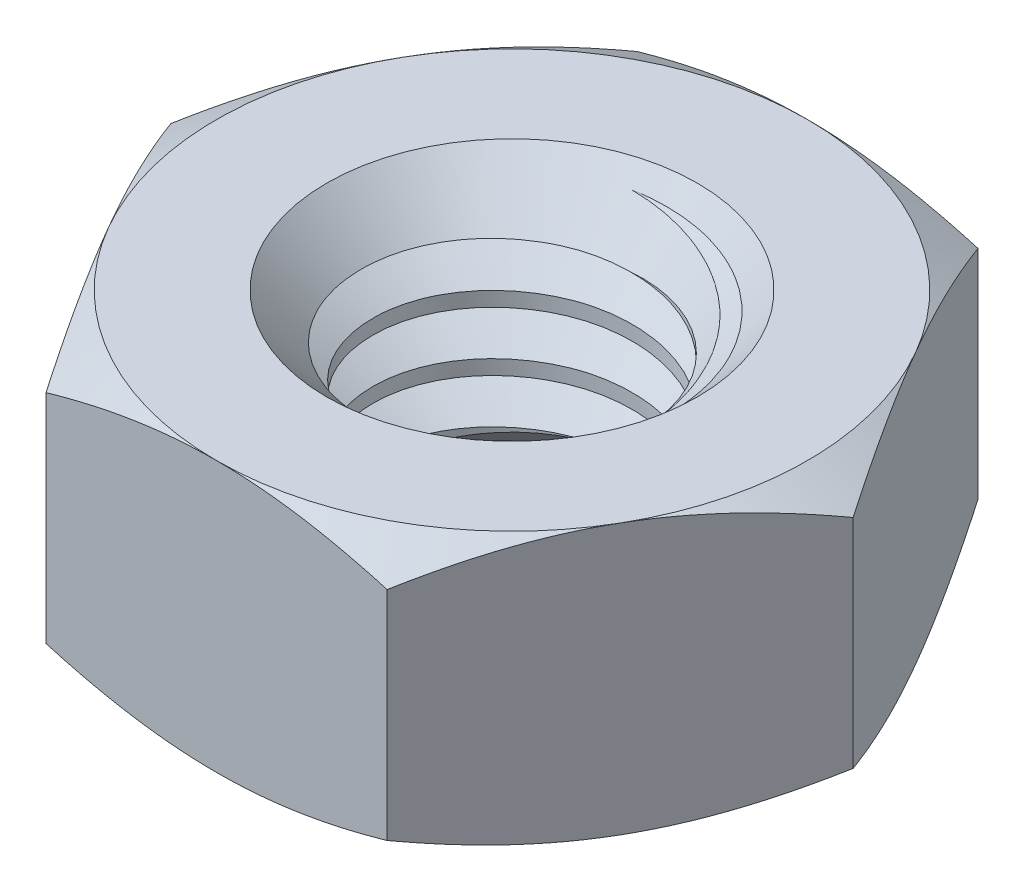
from build123d import *

# Parameters (mm, degrees)
Y_KSEKLIK_EKSTR_ZYON1_DEPTH = 3.2
IZIM2_OUTSIDE_W             = 23.4
IZIM2_OUTSIDE_H             = 22.318
IZIM2_OUTSIDE_R             = 3.5
KES_EKSTR_ZYON1_DEPTH       = 3.2
KES_EKSTR_ZYON1_DRAFT       = -60
IZIM3_OUTSIDE_W             = 23.4
IZIM3_OUTSIDE_H             = 22.318
IZIM3_OUTSIDE_R             = 3.5
KES_EKSTR_ZYON2_DEPTH       = 3.2
KES_EKSTR_ZYON2_DRAFT       = -60
IZIM5_R                     = 1.545
KES_EKSTR_ZYON3_DEPTH       = 3.2
PAH1_SIZE                   = 0.65
KES_S_P_R1_PITCH            = 0.7
KES_S_P_R1_HEIGHT           = 4
KES_S_P_R1_RADIUS           = 1.545
BODY_MOVE_COPY1_ANGLE       = 90


with BuildPart() as part:
    # Çizim1 → Yükseklik-Ekstrüzyon1 (new body)
    with BuildSketch(Plane.XY):
        Polygon((4.041451884, 0), (2.020725942, 3.5), (-2.020725942, 3.5), (-4.041451884, 0), (-2.020725942, -3.5), (2.020725942, -3.5), align=None)
    extrude(amount=Y_KSEKLIK_EKSTR_ZYON1_DEPTH)


with BuildPart() as kes_ekstr_zyon1_tool:
    # Çizim2 outside → Kes-Ekstrüzyon1 (with draft: the straight prism first)
    with BuildSketch(Plane.XY.offset(3.2)):
        Rectangle(IZIM2_OUTSIDE_W, IZIM2_OUTSIDE_H)
        Circle(IZIM2_OUTSIDE_R, mode=Mode.SUBTRACT)
    extrude(amount=-KES_EKSTR_ZYON1_DEPTH)
    # Kes-Ekstrüzyon1: the draft: its side faces are tilted about the plane it starts from
    kes_ekstr_zyon1_sides = [kes_ekstr_zyon1_tool.faces().sort_by_distance(p)[0] for p in [
        (0, -11.159, 1.6),
        (11.7, 0, 1.6),
        (0, 11.159, 1.6),
        (-11.7, 0, 1.6),
        (-3.5, 0, 1.6),
    ]]
    draft(kes_ekstr_zyon1_sides, Plane.XY.offset(3.2), KES_EKSTR_ZYON1_DRAFT)


with BuildPart() as part_1:
    add(part.part)

    # Kes-Ekstrüzyon1: cut by kes_ekstr_zyon1_tool
    add(kes_ekstr_zyon1_tool.part, mode=Mode.SUBTRACT)


with BuildPart() as kes_ekstr_zyon2_tool:
    # Çizim3 outside → Kes-Ekstrüzyon2 (with draft: the straight prism first)
    with BuildSketch(Plane(origin=(0, 0, 0), x_dir=(-1, 0, 0), z_dir=(0, 0, -1))):
        Rectangle(IZIM3_OUTSIDE_W, IZIM3_OUTSIDE_H)
        Circle(IZIM3_OUTSIDE_R, mode=Mode.SUBTRACT)
    extrude(amount=-KES_EKSTR_ZYON2_DEPTH)
    # Kes-Ekstrüzyon2: the draft: its side faces are tilted about the plane it starts from
    kes_ekstr_zyon2_sides = [kes_ekstr_zyon2_tool.faces().sort_by_distance(p)[0] for p in [
        (0, -11.159, 1.6),
        (-11.7, 0, 1.6),
        (0, 11.159, 1.6),
        (11.7, 0, 1.6),
        (3.5, 0, 1.6),
    ]]
    draft(kes_ekstr_zyon2_sides, Plane(origin=(0, 0, 0), x_dir=(-1, 0, 0), z_dir=(0, 0, -1)), KES_EKSTR_ZYON2_DRAFT)


with BuildPart() as part_2:
    add(part_1.part)

    # Kes-Ekstrüzyon2: cut by kes_ekstr_zyon2_tool
    add(kes_ekstr_zyon2_tool.part, mode=Mode.SUBTRACT)

    # Çizim5 → Kes-Ekstrüzyon3 (cut)
    with BuildSketch(Plane(origin=(0, 0, 0), x_dir=(-1, 0, 0), z_dir=(0, 0, -1))):
        Circle(IZIM5_R)
    extrude(amount=-KES_EKSTR_ZYON3_DEPTH, mode=Mode.SUBTRACT)

    # Pah1
    pah1_edges = [part_2.edges().sort_by_distance(p)[0] for p in [
        (1.545, 0, 3.2),
        (1.545, 0, 0),
    ]]
    chamfer(pah1_edges, length=PAH1_SIZE)

    # Kes-Süpür1: sweep along a helix
    with BuildLine() as kes_s_p_r1_path:
        Helix(KES_S_P_R1_PITCH, KES_S_P_R1_HEIGHT, KES_S_P_R1_RADIUS, center=(0, 0, 0), direction=(0, 0, 1))
    # Çizim7 → Kes-Süpür1 (sweep, cut)
    with BuildSketch(Plane(origin=(-0.343794843, -1.506263624, 4), x_dir=(0.07011904852635167, -0.016004215256580363, -0.9974102386319182), z_dir=(0.9724030815382076, -0.22194465783789016, 0.07192229051010418))):
        Polygon((0.347294283, 0.146531344), (-0.347294283, 0.146531344), (0, -0.455), align=None)
    sweep(path=kes_s_p_r1_path.line, is_frenet=True, mode=Mode.SUBTRACT)


with BuildPart() as part_3:
    # Body-Move/Copy1: moved
    add(part_2.part.rotate(Axis((0, 0, 1.642335915), (-1, 0, 0)), BODY_MOVE_COPY1_ANGLE))


solid = part_3.part
